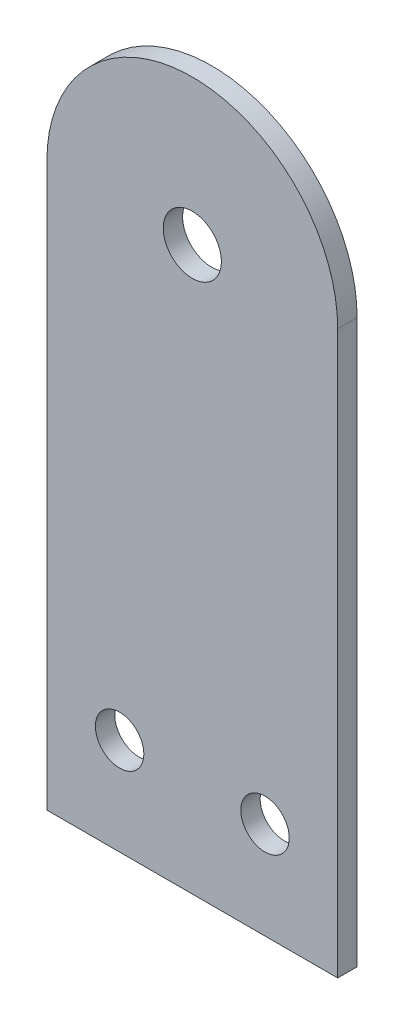
from build123d import *

# Parameters (mm, degrees)
BOSS_EXTRUDE1_DEPTH = 2
SKETCH2_R           = 2.5
SKETCH2_R_2         = 3
CUT_EXTRUDE1_DEPTH  = 2


with BuildPart() as part:
    # Sketch1 → Boss-Extrude1 (new body)
    with BuildSketch(Plane.XY):
        with BuildLine():
            Line((0, 0), (30, 0))
            Line((30, 0), (30, 58))
            ThreePointArc((30, 58), (15, 73), (0, 58))
            Line((0, 58), (0, 0))
        make_face()
    extrude(amount=BOSS_EXTRUDE1_DEPTH)

    # Sketch2 → Cut-Extrude1 (cut)
    with BuildSketch(Plane.XY.offset(2)):
        with Locations((7.5, 10)):
            Circle(SKETCH2_R)
        with Locations((15, 58)):
            Circle(SKETCH2_R_2)
        with Locations((22.5, 10)):
            Circle(SKETCH2_R)
    extrude(amount=-CUT_EXTRUDE1_DEPTH, mode=Mode.SUBTRACT)


solid = part.part
